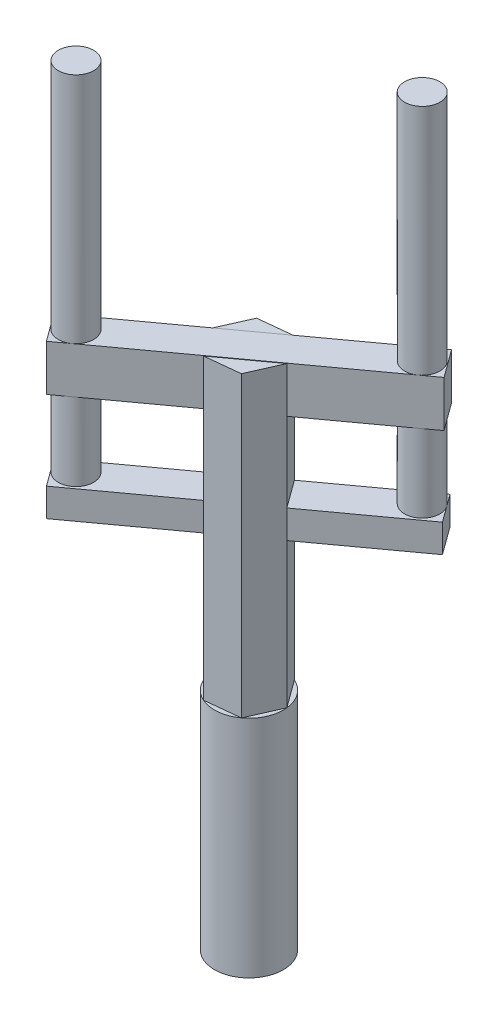
from build123d import *

# Parameters (mm, degrees)
EXTRUDE_1_DEPTH      = 265
SKETCH_3_W           = 30.618601132
SKETCH_3_H           = 40.943060599
EXTRUDE_2_DEPTH      = 100
EXTRUDE_2_DEPTH_BACK = 153
SKETCH_5_R           = 15.723920129
EXTRUDE_3_DEPTH      = 207
EXTRUDE_3_DEPTH_BACK = 110
SKETCH_7_W           = 30.618601132
SKETCH_7_H           = 25.075478903
EXTRUDE_4_DEPTH      = 99
EXTRUDE_4_DEPTH_BACK = 153
SKETCH_8_R           = 30.618601132
EXTRUDE_5_DEPTH      = 200


with BuildPart() as part:
    # Эскиз1 → Бобышка-Вытянуть1 (new body)
    with BuildSketch(Plane(origin=(0, 0, 0), x_dir=(1, 0, 0), z_dir=(0, 1, 0))):
        Polygon((18.014188727, -24.758589212), (30.448661583, 3.22145046), (12.434472856, 27.980039673), (-18.014188727, 24.758589212), (-30.448661583, -3.22145046), (-12.434472856, -27.980039673), align=None)
    extrude(amount=EXTRUDE_1_DEPTH)

    # Эскиз3 → Бобышка-Вытянуть2 (add, two sides)
    with BuildSketch(Plane(origin=(21.44156722, 0, -15.600745066), x_dir=(-0.588341337, 0, -0.808612683), z_dir=(0.808612683, 0, -0.588341337))) as extrude_2_sk:
        with Locations((0, 244.89483014)):
            Rectangle(SKETCH_3_W, SKETCH_3_H)
    extrude(amount=EXTRUDE_2_DEPTH)
    extrude(extrude_2_sk.sketch, amount=-EXTRUDE_2_DEPTH_BACK)

    # Эскиз5 → Бобышка-Вытянуть3 (add, two sides)
    with BuildSketch(Plane(origin=(0, 265.366360439, 0), x_dir=(1, 0, 0), z_dir=(0, 1, 0))) as extrude_3_sk:
        with Locations((-89.323031668, -64.478103556)):
            Circle(SKETCH_5_R)
        with Locations((88.86181825, 65.168036102)):
            Circle(SKETCH_5_R)
    extrude(amount=EXTRUDE_3_DEPTH)
    extrude(extrude_3_sk.sketch, amount=-EXTRUDE_3_DEPTH_BACK)

    # Эскиз7 → Бобышка-Вытянуть4 (add, two sides)
    with BuildSketch(Plane(origin=(21.44156722, 0, -15.600745066), x_dir=(-0.588341337, 0, -0.808612683), z_dir=(0.808612683, 0, -0.588341337))) as extrude_4_sk:
        with Locations((0, 141.302670342)):
            Rectangle(SKETCH_7_W, SKETCH_7_H)
    extrude(amount=EXTRUDE_4_DEPTH)
    extrude(extrude_4_sk.sketch, amount=-EXTRUDE_4_DEPTH_BACK)

    # Эскиз8 → Бобышка-Вытянуть5 (add)
    with BuildSketch(Plane.XZ):
        Circle(SKETCH_8_R)
    extrude(amount=EXTRUDE_5_DEPTH)


solid = part.part
